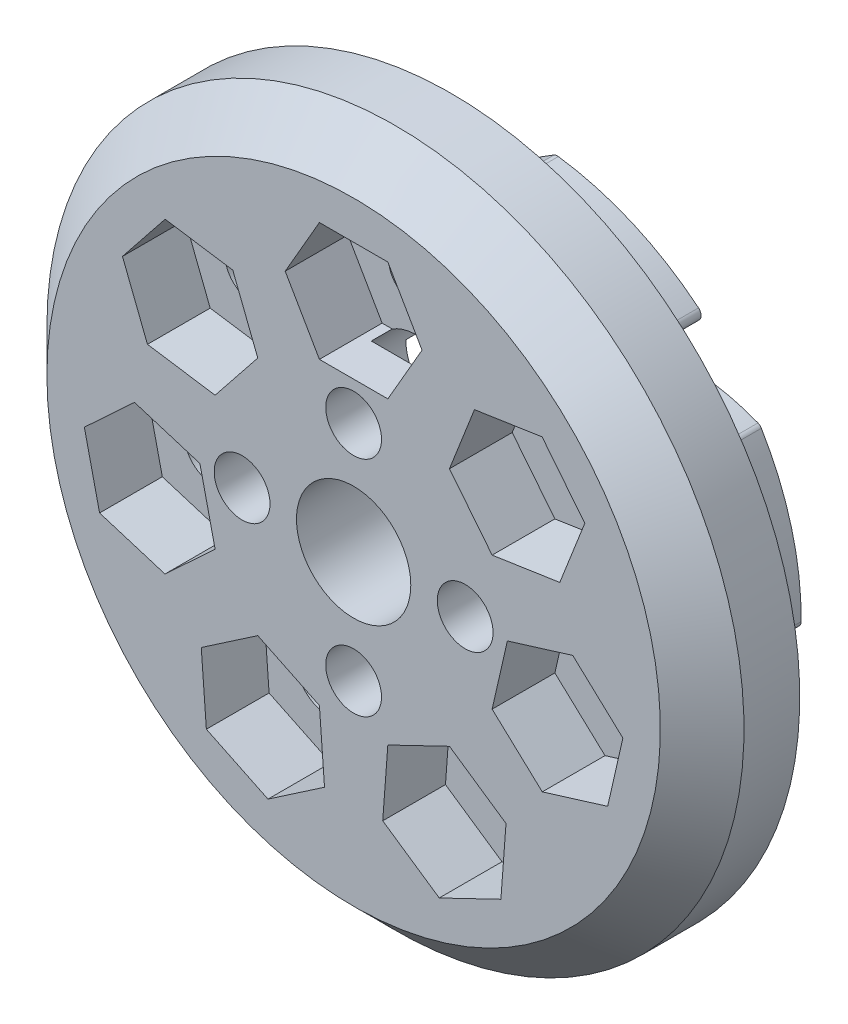
from build123d import *

# Parameters (mm, degrees)
BOSS_EXTRUDE1_START = -1
BOSS_EXTRUDE1_DEPTH = 4
CIRPATTERN1_COUNT   = 7
SKETCH2_R           = 4.1
SKETCH2_R_2         = 2
CUT_EXTRUDE1_DEPTH  = 13.0000001
SKETCH3_R           = 2
CUT_EXTRUDE2_DEPTH  = 13.0000001
CUT_EXTRUDE3_DEPTH  = 4.5
CHAMFER1_SIZE       = 3
SKETCH7_R           = 3.25
CUT_EXTRUDE4_DEPTH  = 9


with BuildPart() as part:
    # Sketch1 → Revolve1 (revolve)
    with BuildSketch(Plane(origin=(0, 0, 0), x_dir=(1, 0, 0), z_dir=(0, 1, 0))):
        Polygon((0, -2), (0, -9), (25, -9), (25, -2), (22.359883264, -2), (19.8, 0), (8.7, 0), (8.7, -2), align=None)
    revolve(axis=Axis((0, 0, 2), (0, 0, 1)))

    # Sketch6 → Boss-Extrude1 (add)
    with BuildSketch(Plane(origin=(0, 0, 0), x_dir=(-1, 0, 0), z_dir=(0, 0, -1)).offset(BOSS_EXTRUDE1_START)):
        with BuildLine():
            ThreePointArc((-12.332877844, 14.665822224), (-12.875383308, 14.948496717), (-12.738275456, 15.544666563))
            ThreePointArc((-12.738275456, 15.544666563), (-8.014988991, 18.429875968), (-2.683804481, 19.917269686))
            ThreePointArc((-2.683804481, 19.917269686), (-2.521336039, 19.912504501), (-2.368980459, 19.855878723))
            ThreePointArc((-2.368980459, 19.855878723), (0.23086084, 17.950872792), (2.33647904, 15.510669034))
            ThreePointArc((2.33647904, 15.510669034), (3.612769689, 12.272459168), (3.365747106, 8.800586359))
            ThreePointArc((3.365747106, 8.800586359), (3.119088936, 8.502608228), (2.733662989, 8.469774418))
            ThreePointArc((2.733662989, 8.469774418), (2.516384179, 8.536849557), (2.297462648, 8.598351744))
            ThreePointArc((2.297462648, 8.598351744), (2.140937943, 8.670996646), (2.018430233, 8.79252494))
            ThreePointArc((2.018430233, 8.79252494), (-4.302662055, 13.817281567), (-12.332877844, 14.665822224))
        make_face()
    boss_extrude1 = extrude(amount=BOSS_EXTRUDE1_DEPTH)

    # CirPattern1: Boss-Extrude1 ×7 about axis
    cirpattern1_axis = Axis((0, 0, 0), (0, 0, 1))
    for i in range(1, CIRPATTERN1_COUNT):
        add(boss_extrude1.rotate(cirpattern1_axis, i * 360 / CIRPATTERN1_COUNT))

    # Sketch2 → Cut-Extrude1 (cut, through all)
    with BuildSketch(Plane.XY.offset(9)):
        Circle(SKETCH2_R)
        with Locations((0, 8)):
            Circle(SKETCH2_R_2)
        with Locations((8, 0)):
            Circle(SKETCH2_R_2)
        with Locations((0, -8)):
            Circle(SKETCH2_R_2)
        with Locations((-8, 0)):
            Circle(SKETCH2_R_2)
    extrude(amount=-CUT_EXTRUDE1_DEPTH, mode=Mode.SUBTRACT)

    # Sketch3 → Cut-Extrude2 (cut, through all)
    with BuildSketch(Plane.XY.offset(9)):
        with Locations((0, 15)):
            Circle(SKETCH3_R)
        with Locations((11.727472237, 9.352347028)):
            Circle(SKETCH3_R)
        with Locations((14.623918683, -3.337814009)):
            Circle(SKETCH3_R)
        with Locations((6.508256087, -13.514533019)):
            Circle(SKETCH3_R)
        with Locations((-6.508256087, -13.514533019)):
            Circle(SKETCH3_R)
        with Locations((-14.623918683, -3.337814009)):
            Circle(SKETCH3_R)
        with Locations((-11.727472237, 9.352347028)):
            Circle(SKETCH3_R)
    extrude(amount=-CUT_EXTRUDE2_DEPTH, mode=Mode.SUBTRACT)

    # Sketch4 → Cut-Extrude3 (cut)
    with BuildSketch(Plane.XY.offset(9)):
        Polygon((8.667710195, 13.189167271), (6.874807416, 8.620925492), (9.934569458, 4.784105248), (14.787234279, 5.515526785), (16.580137059, 10.083768564), (13.520375017, 13.920588807), align=None)
        Polygon((2.453738644, 19.25), (-2.453738644, 19.25), (-4.907477288, 15), (-2.453738644, 10.75), (2.453738644, 10.75), (4.907477288, 15), align=None)
        Polygon((15.715935112, 1.446622577), (11.026483271, 0.000118253), (9.934466841, -4.784318333), (13.531902253, -8.122250596), (18.221354095, -6.675746272), (19.313370524, -1.891309685), align=None)
        Polygon((10.929740343, -11.385258423), (6.874992324, -8.620778032), (2.453508067, -10.750052628), (2.08677183, -15.643807614), (6.14151985, -18.408288005), (10.563004106, -16.279013409), align=None)
        Polygon((-2.08677183, -15.643807614), (-2.453508067, -10.750052628), (-6.874992324, -8.620778032), (-10.929740343, -11.385258423), (-10.563004106, -16.279013409), (-6.14151985, -18.408288005), align=None)
        Polygon((-13.531902253, -8.122250596), (-9.934466841, -4.784318333), (-11.026483271, 0.000118253), (-15.715935112, 1.446622577), (-19.313370524, -1.891309685), (-18.221354095, -6.675746272), align=None)
        Polygon((-14.787234279, 5.515526785), (-9.934569458, 4.784105248), (-6.874807416, 8.620925492), (-8.667710195, 13.189167271), (-13.520375017, 13.920588807), (-16.580137059, 10.083768564), align=None)
    extrude(amount=-CUT_EXTRUDE3_DEPTH, mode=Mode.SUBTRACT)

    # Chamfer1
    chamfer1_edges = [part.edges().sort_by_distance(p)[0] for p in [
        (-25, 0, 9),
    ]]
    chamfer(chamfer1_edges, length=CHAMFER1_SIZE)

    # Sketch7 → Cut-Extrude4 (cut)
    with BuildSketch(Plane(origin=(0, 0, -3), x_dir=(-1, 0, 0), z_dir=(0, 0, -1))):
        with Locations((0, 8)):
            Circle(SKETCH7_R)
        with Locations((8, 0)):
            Circle(SKETCH7_R)
        with Locations((0, -8)):
            Circle(SKETCH7_R)
        with Locations((-8, 0)):
            Circle(SKETCH7_R)
    extrude(amount=-CUT_EXTRUDE4_DEPTH, mode=Mode.SUBTRACT)


solid = part.part
